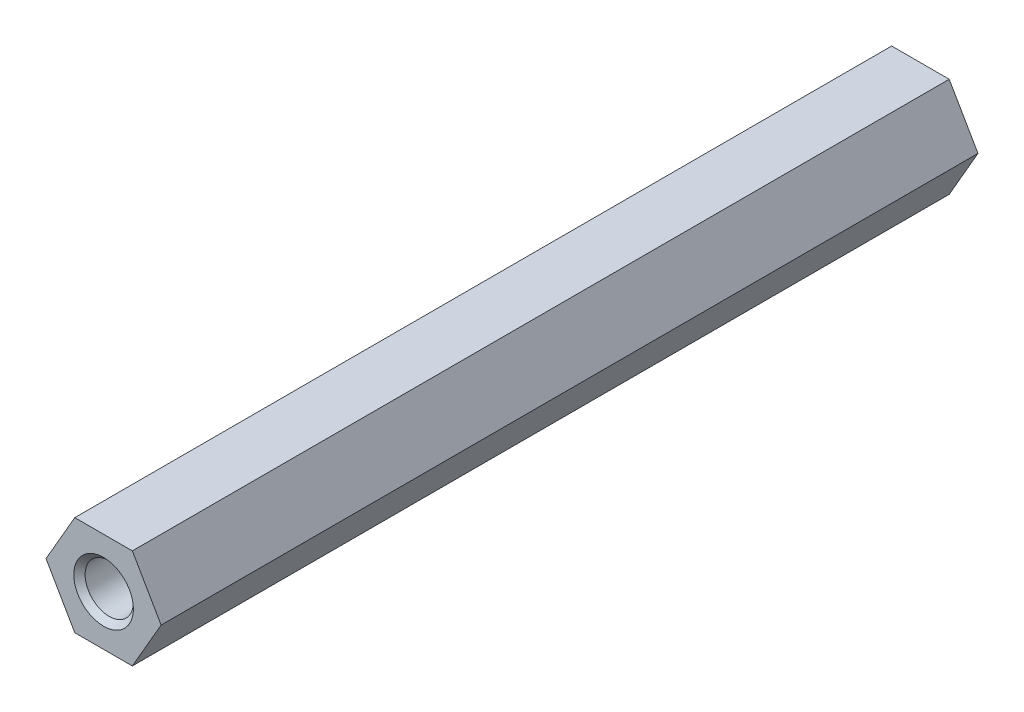
from build123d import *

# Parameters (mm, degrees)
EXTRUDE1_DEPTH        = 50.8
F_6_32_TAPPED_HOLE8_D = 2.7051
CHAMFER1_SIZE         = 0.5
CHAMFER2_SIZE         = 0.5
SKETCH15_R            = 1.5
CUT_EXTRUDE1_DEPTH    = 51.8


with BuildPart() as part:
    # Sketch1 → Extrude1 (new body)
    with BuildSketch(Plane.XY):
        Polygon((3.579571669, 0), (1.789785834, 3.1), (-1.789785834, 3.1), (-3.579571669, 0), (-1.789785834, -3.1), (1.789785834, -3.1), align=None)
    extrude(amount=-EXTRUDE1_DEPTH)

    # #6-32 Tapped Hole8 (through all)
    with Locations(Plane(origin=(0.000428254, 0.000741758, 0), x_dir=(1, 0, 0), z_dir=(0, 0, 1))):
        with Locations((0, 0)):
            Hole(F_6_32_TAPPED_HOLE8_D / 2)

    # Chamfer1
    chamfer1_edges = [part.edges().sort_by_distance(p)[0] for p in [
        (1.352978254, 0.000741758, 0),
    ]]
    chamfer(chamfer1_edges, length=CHAMFER1_SIZE)

    # Chamfer2
    chamfer2_edges = [part.edges().sort_by_distance(p)[0] for p in [
        (1.352978254, 0.000741758, -50.8),
    ]]
    chamfer(chamfer2_edges, length=CHAMFER2_SIZE)

    # Sketch15 → Cut-Extrude1 (cut, through all)
    with BuildSketch(Plane.XY):
        Circle(SKETCH15_R)
    extrude(amount=-CUT_EXTRUDE1_DEPTH, mode=Mode.SUBTRACT)


solid = part.part
